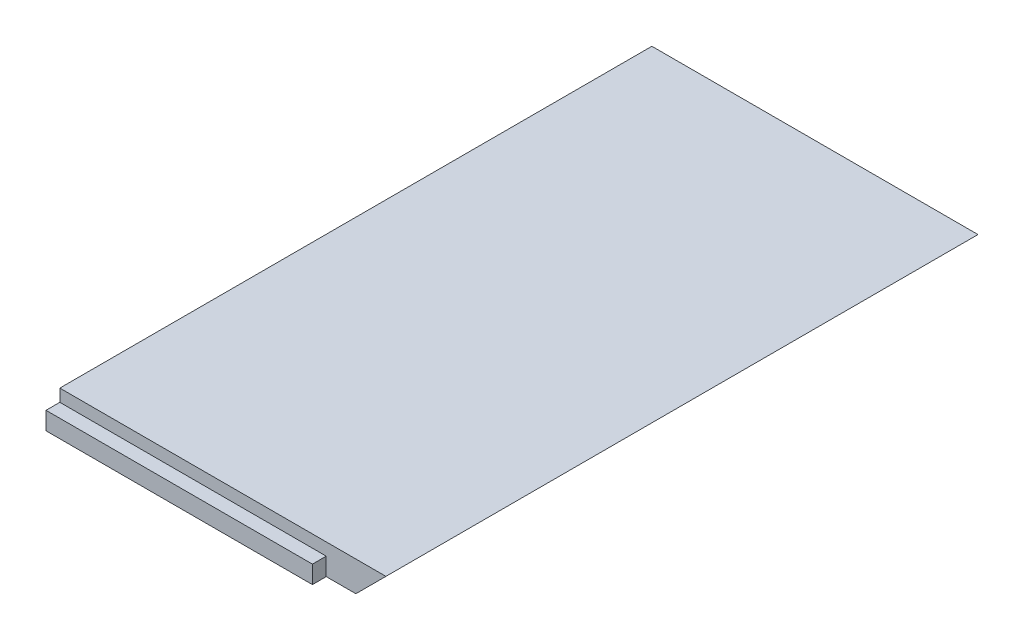
from build123d import *

# Parameters (mm, degrees)
ESQUISSE1_W                         = 165.25
ESQUISSE1_H                         = 15.25
BOSS_EXTRU_1_DEPTH                  = 300
ESQUISSE3_W                         = 7
ESQUISSE3_H                         = 9
BOSS_EXTRU_4_DEPTH                  = 165.25
ENL_V_MAT_EXTRU_2_REACH             = 302
ENL_V_MAT_EXTRU_2_DIRECTION_2_REACH = 9
ESQUISSE4_W                         = 24
ESQUISSE4_H                         = 9
ENL_V_MAT_EXTRU_3_DEPTH             = 7


with BuildPart() as part:
    # Esquisse1 → Boss.-Extru.1 (new body)
    with BuildSketch(Plane.XY):
        with Locations((-382.625, 177.688864629)):
            Rectangle(ESQUISSE1_W, ESQUISSE1_H)
    extrude(amount=BOSS_EXTRU_1_DEPTH)

    # Esquisse3 → Boss.-Extru.4 (add)
    with BuildSketch(Plane.ZY.offset(465.25)):
        with Locations((303.5, 174.563864629)):
            Rectangle(ESQUISSE3_W, ESQUISSE3_H)
    extrude(amount=-BOSS_EXTRU_4_DEPTH)

    # Esquisse2 → Enlèv. mat.-Extru.2 (cut, up to next)
    with BuildSketch(Plane.XY.offset(300), mode=Mode.PRIVATE) as enl_v_mat_extru_2_sk1:
        Polygon((-300, 185.313864629), (-315.25, 170.063864629), (-300, 170.063864629), align=None)
    enl_v_mat_extru_2_tool1 = extrude(enl_v_mat_extru_2_sk1.sketch, amount=-ENL_V_MAT_EXTRU_2_REACH, mode=Mode.PRIVATE) & part.part
    add(enl_v_mat_extru_2_tool1.solids().sort_by_distance((-305.083333, 175.147198, 300))[0], mode=Mode.SUBTRACT)

    # Esquisse2 → Enlèv. mat.-Extru.2 direction 2 (cut, up to next)
    with BuildSketch(Plane.XY.offset(300), mode=Mode.PRIVATE) as enl_v_mat_extru_2_direction_2_sk1:
        Polygon((-300, 185.313864629), (-315.25, 170.063864629), (-300, 170.063864629), align=None)
    enl_v_mat_extru_2_direction_2_tool1 = extrude(enl_v_mat_extru_2_direction_2_sk1.sketch, amount=ENL_V_MAT_EXTRU_2_DIRECTION_2_REACH, mode=Mode.PRIVATE) & part.part
    add(enl_v_mat_extru_2_direction_2_tool1.solids().sort_by_distance((-305.083333, 175.147198, 300))[0], mode=Mode.SUBTRACT)

    # Esquisse4 → Enlèv. mat.-Extru.3 (cut)
    with BuildSketch(Plane.XY.offset(307)):
        with Locations((-318.25, 174.563864629)):
            Rectangle(ESQUISSE4_W, ESQUISSE4_H)
    extrude(amount=-ENL_V_MAT_EXTRU_3_DEPTH, mode=Mode.SUBTRACT)


solid = part.part
